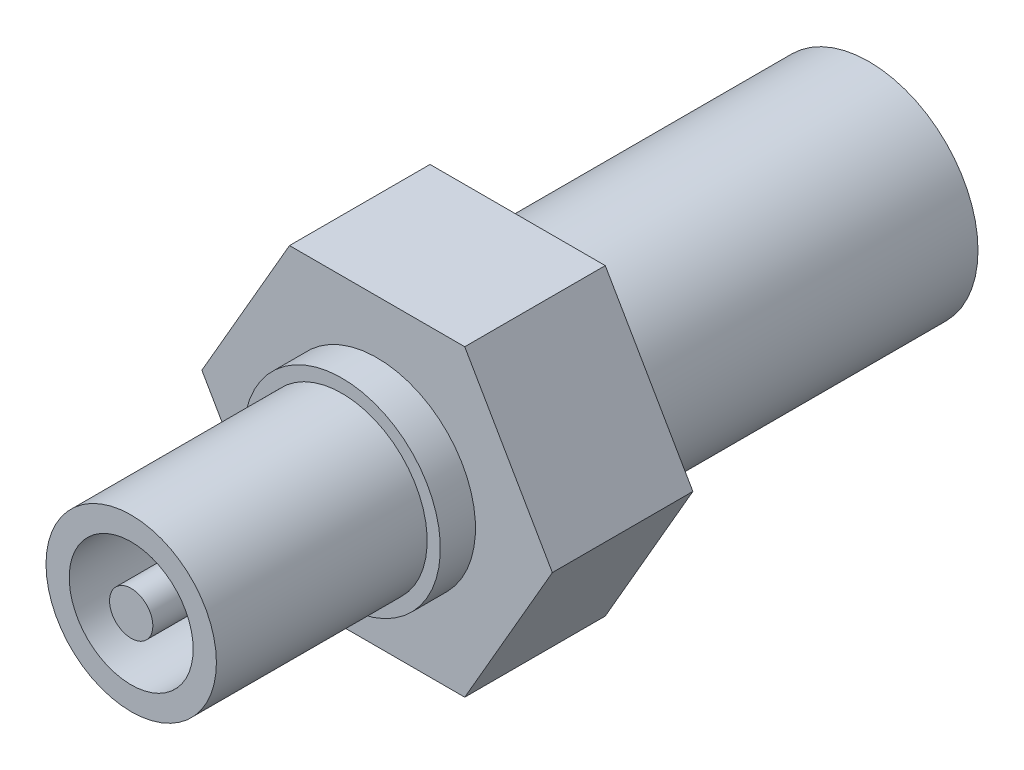
from build123d import *

# Parameters (mm, degrees)
SKETCH1_R          = 3.85
EXTRUDE1_DEPTH     = 9.525
SKETCH2_R          = 4.445
EXTRUDE2_DEPTH     = 1.5875
EXTRUDE3_DEPTH     = 6.35
SKETCH4_R          = 4.9276
EXTRUDE4_DEPTH     = 15.875
SKETCH5_R          = 2.80042078
SKETCH5_R_2        = 0.97787642
CUT_EXTRUDE1_DEPTH = 9.525


with BuildPart() as part:
    # Sketch1 → Extrude1 (new body)
    with BuildSketch(Plane.XY):
        Circle(SKETCH1_R)
    extrude(amount=EXTRUDE1_DEPTH)

    # Sketch2 → Extrude2 (add)
    with BuildSketch(Plane(origin=(0, 0, 0), x_dir=(-1, 0, 0), z_dir=(0, 0, -1))):
        Circle(SKETCH2_R)
    extrude(amount=EXTRUDE2_DEPTH)

    # Sketch3 → Extrude3 (add)
    with BuildSketch(Plane(origin=(0, 0, -1.5875), x_dir=(-1, 0, 0), z_dir=(0, 0, -1))):
        Polygon((-3.959468146, 6.858), (3.959468146, 6.858), (7.918936292, 0), (3.959468146, -6.858), (-3.959468146, -6.858), (-7.918936292, 0), align=None)
    extrude(amount=EXTRUDE3_DEPTH)

    # Sketch4 → Extrude4 (add)
    with BuildSketch(Plane(origin=(0, 0, -7.9375), x_dir=(-1, 0, 0), z_dir=(0, 0, -1))):
        Circle(SKETCH4_R)
    extrude(amount=EXTRUDE4_DEPTH)

    # Sketch5 → Cut-Extrude1 (cut)
    with BuildSketch(Plane.XY.offset(9.525)):
        Circle(SKETCH5_R)
        Circle(SKETCH5_R_2, mode=Mode.SUBTRACT)
    extrude(amount=-CUT_EXTRUDE1_DEPTH, mode=Mode.SUBTRACT)


solid = part.part
